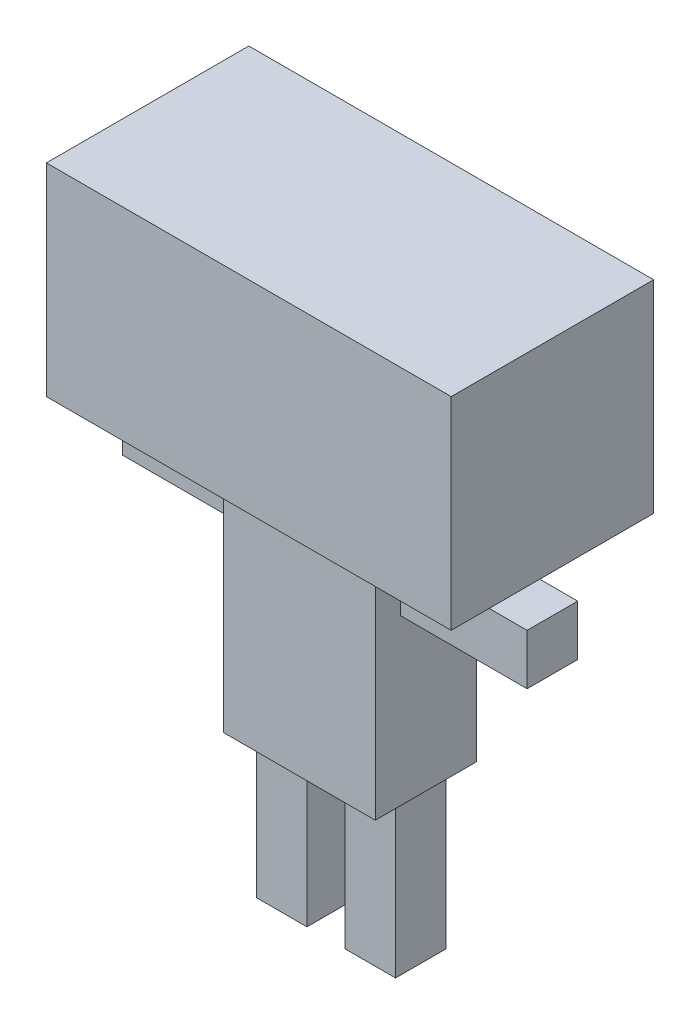
from build123d import *

# Parameters (mm, degrees)
BOSS_EXTRUDE1_DEPTH      = 400
BOSS_EXTRUDE1_DEPTH_BACK = 400
SKETCH1_W                = 1600
SKETCH1_H                = 800
BOSS_EXTRUDE2_DEPTH      = 200
BOSS_EXTRUDE2_DEPTH_BACK = 200
SKETCH2_W                = 600
SKETCH2_H                = 1000
BOSS_EXTRUDE3_DEPTH      = 100
BOSS_EXTRUDE3_DEPTH_BACK = 100
SKETCH3_W                = 200
SKETCH3_H                = 600
SKETCH4_W                = 200
SKETCH4_H                = 200
BOSS_EXTRUDE4_DEPTH      = 500
SKETCH5_R                = 100
BOSS_EXTRUDE5_DEPTH      = 100


with BuildPart() as part:
    # Sketch1 → Boss-Extrude1 (new, two sides: drawn at the far end of the back side and taken through both)
    with BuildSketch(Plane.XY.offset(-BOSS_EXTRUDE1_DEPTH_BACK)):
        with Locations((0, 900)):
            Rectangle(SKETCH1_W, SKETCH1_H)
    extrude(amount=BOSS_EXTRUDE1_DEPTH + BOSS_EXTRUDE1_DEPTH_BACK)

    # Sketch2 → Boss-Extrude2 (add, two sides: drawn at the far end of the back side and taken through both)
    with BuildSketch(Plane.XY.offset(-BOSS_EXTRUDE2_DEPTH_BACK)):
        Rectangle(SKETCH2_W, SKETCH2_H)
    extrude(amount=BOSS_EXTRUDE2_DEPTH + BOSS_EXTRUDE2_DEPTH_BACK)

    # Sketch3 → Boss-Extrude3 (add, two sides: drawn at the far end of the back side and taken through both)
    with BuildSketch(Plane.XY.offset(-BOSS_EXTRUDE3_DEPTH_BACK)):
        with Locations((-170, -800)):
            Rectangle(SKETCH3_W, SKETCH3_H)
        with Locations((180, -800)):
            Rectangle(SKETCH3_W, SKETCH3_H)
    extrude(amount=BOSS_EXTRUDE3_DEPTH + BOSS_EXTRUDE3_DEPTH_BACK)

    # Sketch4 → Boss-Extrude4 (add)
    with BuildSketch(Plane.ZY.offset(300)):
        with Locations((0, 250)):
            Rectangle(SKETCH4_W, SKETCH4_H)
    boss_extrude4 = extrude(amount=BOSS_EXTRUDE4_DEPTH)

    # Mirror1: Boss-Extrude4 across plane
    add(boss_extrude4.mirror(Plane(origin=(0, 0, 0), x_dir=(0, 0, 1), z_dir=(1, 0, 0))))

    # Sketch5 → Boss-Extrude5 (add)
    with BuildSketch(Plane(origin=(0, 0, -400), x_dir=(-1, 0, 0), z_dir=(0, 0, -1))):
        with Locations((-300, 1000)):
            Circle(SKETCH5_R)
        with Locations((300, 1000)):
            Circle(SKETCH5_R)
        Polygon((0, 800), (-141.421356237, 658.578643763), (141.421356237, 658.578643763), align=None)
    extrude(amount=BOSS_EXTRUDE5_DEPTH)


solid = part.part
